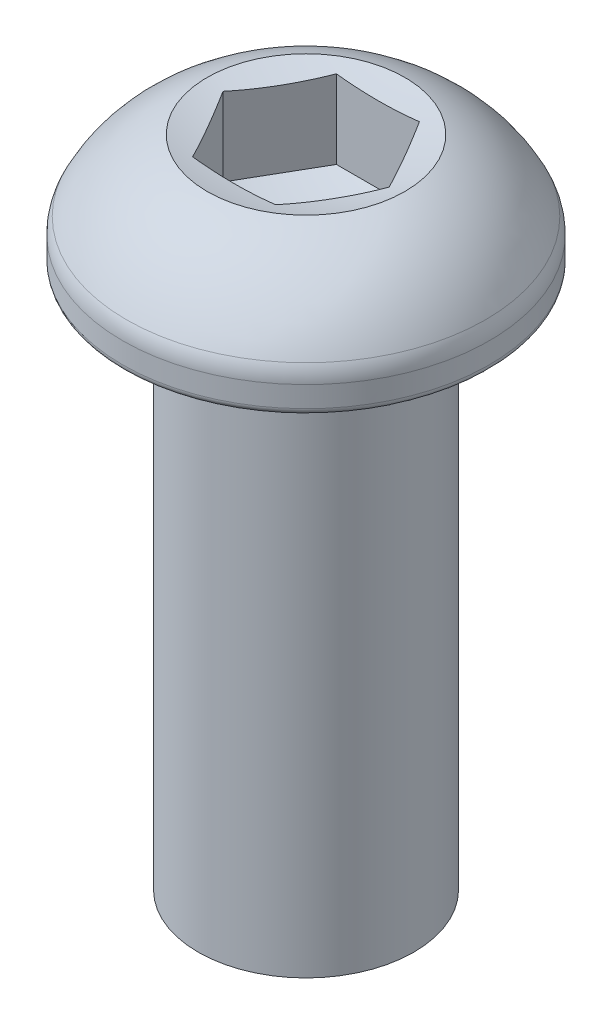
from build123d import *

# Parameters (mm, degrees)
FILLET1_R           = 0.2
FILLET2_R           = 1
SKETCH2_R           = 3
BOSS_EXTRUDE1_DEPTH = 15
CUT_EXTRUDE1_DEPTH  = 2.3


with BuildPart() as part:
    # Sketch1 → Revolve1 (revolve)
    with BuildSketch(Plane.XY):
        with BuildLine():
            Line((0, 0), (5.1, 0))
            Line((5.1, 0), (5.1, 1))
            ThreePointArc((5.1, 1), (4.1560785, 2.346833852), (2.75, 3.2))
            Line((2.75, 3.2), (0, 3.2))
            Line((0, 3.2), (0, 0))
        make_face()
    revolve(axis=Axis((0, 55, 0), (0, -1, 0)))

    # Fillet1
    fillet1_edges = [part.edges().sort_by_distance(p)[0] for p in [
        (-5.1, 0, 0),
    ]]
    fillet(fillet1_edges, radius=FILLET1_R)

    # Fillet2
    fillet2_edges = [part.edges().sort_by_distance(p)[0] for p in [
        (-5.1, 1, 0),
    ]]
    fillet(fillet2_edges, radius=FILLET2_R)

    # Sketch2 → Boss-Extrude1 (add)
    with BuildSketch(Plane.XZ):
        Circle(SKETCH2_R)
    extrude(amount=BOSS_EXTRUDE1_DEPTH)

    # Sketch6 → Revolve2 (revolve)
    with BuildSketch(Plane.XY):
        Polygon((0, 0), (0, 3.2), (2.75, 3.2), (4.9, 0), align=None)
    revolve(axis=Axis((0, 55, 0), (0, -1, 0)))

    # Sketch7 → Cut-Extrude1 (cut)
    with BuildSketch(Plane(origin=(0, 3.2, 0), x_dir=(1, 0, 0), z_dir=(0, 1, 0))):
        Polygon((1.154700538, -2), (2.309401077, 0), (1.154700538, 2), (-1.154700538, 2), (-2.309401077, 0), (-1.154700538, -2), align=None)
    extrude(amount=-CUT_EXTRUDE1_DEPTH, mode=Mode.SUBTRACT)

    # Sketch8 → Cut-Revolve1 (revolve, cut)
    with BuildSketch(Plane.XY):
        with BuildLine():
            Line((0, 0.9), (0, 0.5))
            Line((0, 0.5), (0.25, 0.5))
            ThreePointArc((0.25, 0.5), (1.298943849, 0.600925763), (2.309401077, 0.9))
            Line((2.309401077, 0.9), (0, 0.9))
        make_face()
    revolve(axis=Axis((0, 55, 0), (0, -1, 0)), mode=Mode.SUBTRACT)

    # Sketch9 → Cut-Revolve2 (revolve, cut)
    with BuildSketch(Plane.XY):
        with BuildLine():
            ThreePointArc((0, 2.814442262), (1.388448304, 2.911300775), (2.75, 3.2))
            Line((2.75, 3.2), (0, 3.2))
            Line((0, 3.2), (0, 2.814442262))
        make_face()
    revolve(axis=Axis((0, 55, 0), (0, -1, 0)), mode=Mode.SUBTRACT)


solid = part.part
